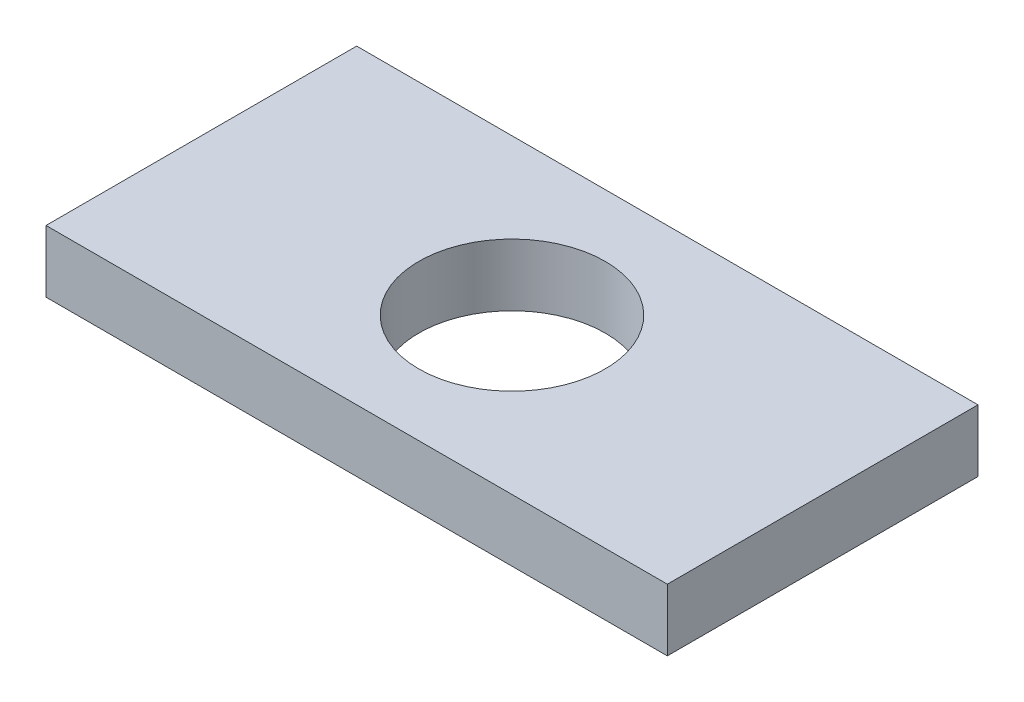
from build123d import *

# Parameters (mm, degrees)
SKETCH_1_W          = 40
SKETCH_1_H          = 20
EXTRUDE_1_DEPTH     = 4
SKETCH_2_R          = 6
CUT_EXTRUDE_1_DEPTH = 5


with BuildPart() as part:
    # Эскиз1 → Бобышка-Вытянуть1 (new body)
    with BuildSketch(Plane(origin=(0, 0, 0), x_dir=(1, 0, 0), z_dir=(0, 1, 0))):
        with Locations((20, 10)):
            Rectangle(SKETCH_1_W, SKETCH_1_H)
    extrude(amount=EXTRUDE_1_DEPTH)

    # Эскиз2 → Вырез-Вытянуть1 (cut, through all)
    with BuildSketch(Plane(origin=(0, 4, 0), x_dir=(1, 0, 0), z_dir=(0, 1, 0))):
        with Locations((20, 10)):
            Circle(SKETCH_2_R)
    extrude(amount=-CUT_EXTRUDE_1_DEPTH, mode=Mode.SUBTRACT)


solid = part.part
